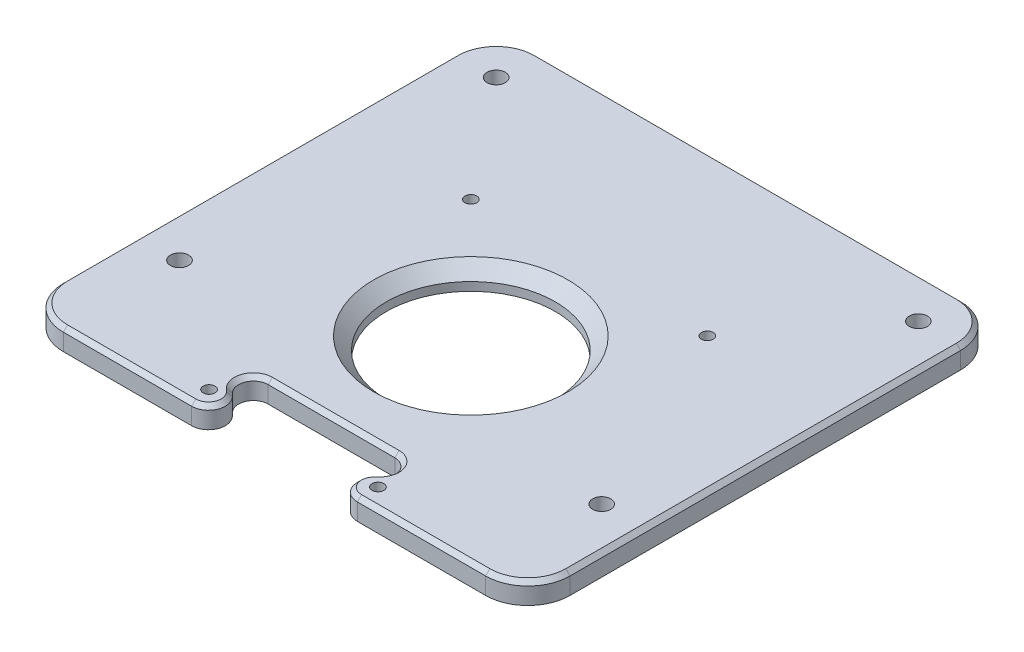
from build123d import *

# Parameters (mm, degrees)
SKETCH2_W           = 120
SKETCH2_H           = 112.5
BOSS_EXTRUDE2_DEPTH = 5
CUT_EXTRUDE7_DEPTH  = 6
FILLET5_R           = 10
SKETCH10_R          = 20
CUT_EXTRUDE9_DEPTH  = 6
CHAMFER3_SIZE       = 3
FILLET6_R           = 4
CHAMFER4_SIZE       = 1
SKETCH11_R          = 2.15
CUT_EXTRUDE10_DEPTH = 6
SKETCH1_R           = 1.4
CUT_EXTRUDE13_DEPTH = 5
SKETCH13_R          = 2.875
CUT_EXTRUDE12_DEPTH = 2.5


with BuildPart() as part:
    # Sketch2 → Boss-Extrude2 (new body)
    with BuildSketch(Plane(origin=(0, 0, 0), x_dir=(1, 0, 0), z_dir=(0, 1, 0))):
        with Locations((0, 9.75)):
            Rectangle(SKETCH2_W, SKETCH2_H)
    extrude(amount=BOSS_EXTRUDE2_DEPTH)

    # Sketch9 → Cut-Extrude7 (cut, through all)
    with BuildSketch(Plane(origin=(0, 5, 0), x_dir=(1, 0, 0), z_dir=(0, 1, 0))):
        with BuildLine():
            ThreePointArc((-15, -33), (-18.232806931, -35.158747099), (-17.477720957, -38.972023232))
            Line((-17.477720957, -38.972023232), (-10.196302495, -46.5))
            Line((-10.196302495, -46.5), (10.196302495, -46.5))
            Line((10.196302495, -46.5), (17.477720957, -38.972023232))
            ThreePointArc((17.477720957, -38.972023232), (18.232806931, -35.158747099), (15, -33))
            Line((15, -33), (-15, -33))
        make_face()
    extrude(amount=-CUT_EXTRUDE7_DEPTH, mode=Mode.SUBTRACT)

    # Fillet5
    fillet5_edges = [part.edges().sort_by_distance(p)[0] for p in [
        (-60, 2.5, -66),
        (60, 2.5, -66),
        (60, 2.5, 46.5),
        (-60, 2.5, 46.5),
    ]]
    fillet(fillet5_edges, radius=FILLET5_R)

    # Sketch10 → Cut-Extrude9 (cut, through all)
    with BuildSketch(Plane(origin=(0, 0, 0), x_dir=(1, 0, 0), z_dir=(0, 1, 0))):
        Circle(SKETCH10_R)
    extrude(amount=CUT_EXTRUDE9_DEPTH, mode=Mode.SUBTRACT)

    # Chamfer3
    chamfer3_edges = [part.edges().sort_by_distance(p)[0] for p in [
        (-20, 5, 0),
    ]]
    chamfer(chamfer3_edges, length=CHAMFER3_SIZE)

    # Fillet6
    fillet6_edges = [part.edges().sort_by_distance(p)[0] for p in [
        (10.196302495, 2.5, 46.5),
        (-10.196302495, 2.5, 46.5),
    ]]
    fillet(fillet6_edges, radius=FILLET6_R)

    # Chamfer4
    chamfer4_edges = [part.edges().sort_by_distance(p)[0] for p in [
        (18.232806931, 5, 35.158747099),
        (17.116441895, 5, 39.345535673),
        (-18.232806931, 5, 35.158747099),
        (0, 5, 33),
        (-17.116441895, 5, 39.345535673),
        (-60, 5, -9.75),
        (0, 5, -66),
        (60, 5, -9.75),
        (-34.815140686, 5, 46.5),
        (-57.071067812, 5, 43.571067812),
        (57.071067812, 5, 43.571067812),
        (57.071067812, 5, -63.071067812),
        (-57.071067812, 5, -63.071067812),
        (34.815140686, 5, 46.5),
        (15.947632356, 5, 44.061440433),
        (-15.947632356, 5, 44.061440433),
    ]]
    chamfer(chamfer4_edges, length=CHAMFER4_SIZE)

    # Sketch11 → Cut-Extrude10 (cut, through all)
    with BuildSketch(Plane(origin=(0, 5, 0), x_dir=(1, 0, 0), z_dir=(0, 1, 0))):
        with Locations((-50, 56)):
            Circle(SKETCH11_R)
        with Locations((50, 56)):
            Circle(SKETCH11_R)
        with Locations((-50, -19)):
            Circle(SKETCH11_R)
        with Locations((50, -19)):
            Circle(SKETCH11_R)
    extrude(amount=-CUT_EXTRUDE10_DEPTH, mode=Mode.SUBTRACT)

    # Sketch1 → Cut-Extrude13 (cut)
    with BuildSketch(Plane(origin=(0, 0, 0), x_dir=(1, 0, 0), z_dir=(0, 1, 0))):
        with Locations((-20, -42)):
            Circle(SKETCH1_R)
        with Locations((20, -42)):
            Circle(SKETCH1_R)
        with Locations((28, 28)):
            Circle(SKETCH1_R)
        with Locations((-28, 28)):
            Circle(SKETCH1_R)
    extrude(amount=CUT_EXTRUDE13_DEPTH, mode=Mode.SUBTRACT)

    # Sketch13 → Cut-Extrude12 (cut)
    with BuildSketch(Plane.XZ):
        with Locations((-20, 42)):
            Circle(SKETCH13_R)
        with Locations((20, 42)):
            Circle(SKETCH13_R)
        with Locations((-28, -28)):
            Circle(SKETCH13_R)
        with Locations((28, -28)):
            Circle(SKETCH13_R)
    extrude(amount=-CUT_EXTRUDE12_DEPTH, mode=Mode.SUBTRACT)


solid = part.part
